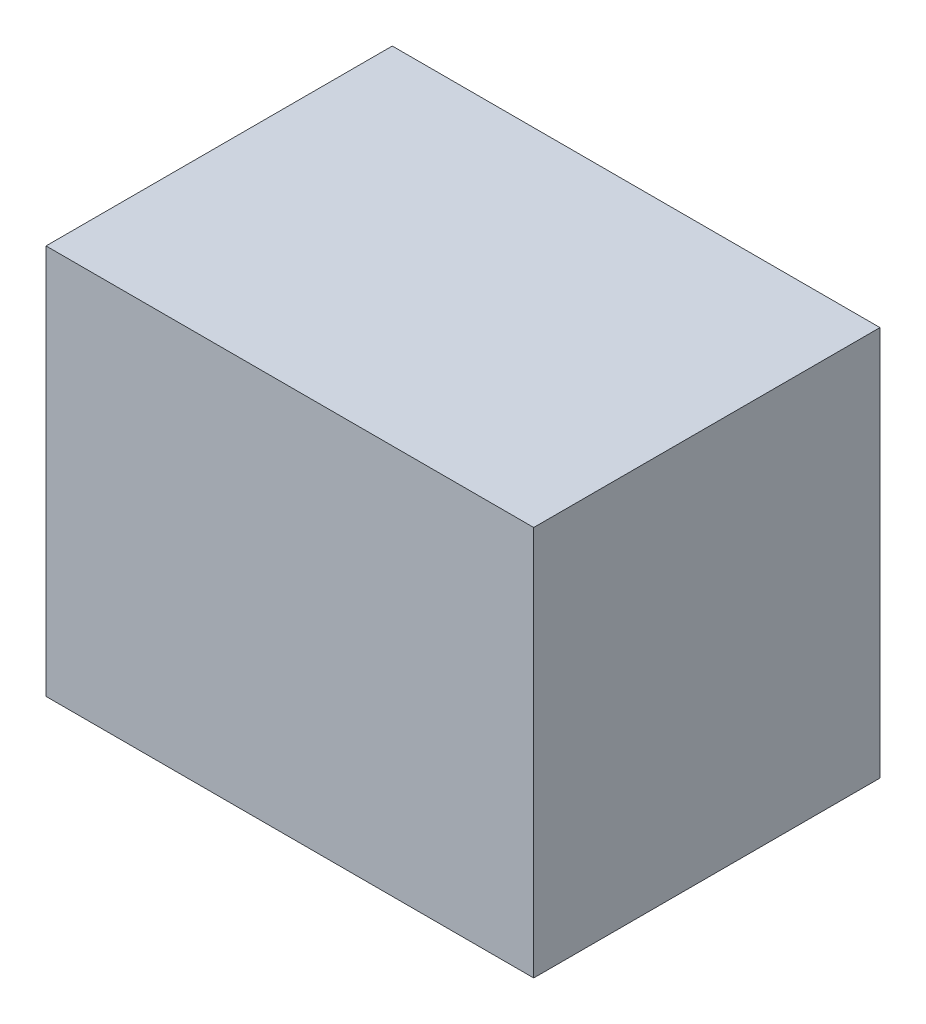
from build123d import *

# Parameters (mm, degrees)
SKETCH1_W           = 50
SKETCH1_H           = 40
BOSS_EXTRUDE1_DEPTH = 35.5


with BuildPart() as part:
    # Sketch1 → Boss-Extrude1 (new body)
    with BuildSketch(Plane.XY):
        with Locations((-13.5, 58.6)):
            Rectangle(SKETCH1_W, SKETCH1_H)
    extrude(amount=-BOSS_EXTRUDE1_DEPTH)


solid = part.part
